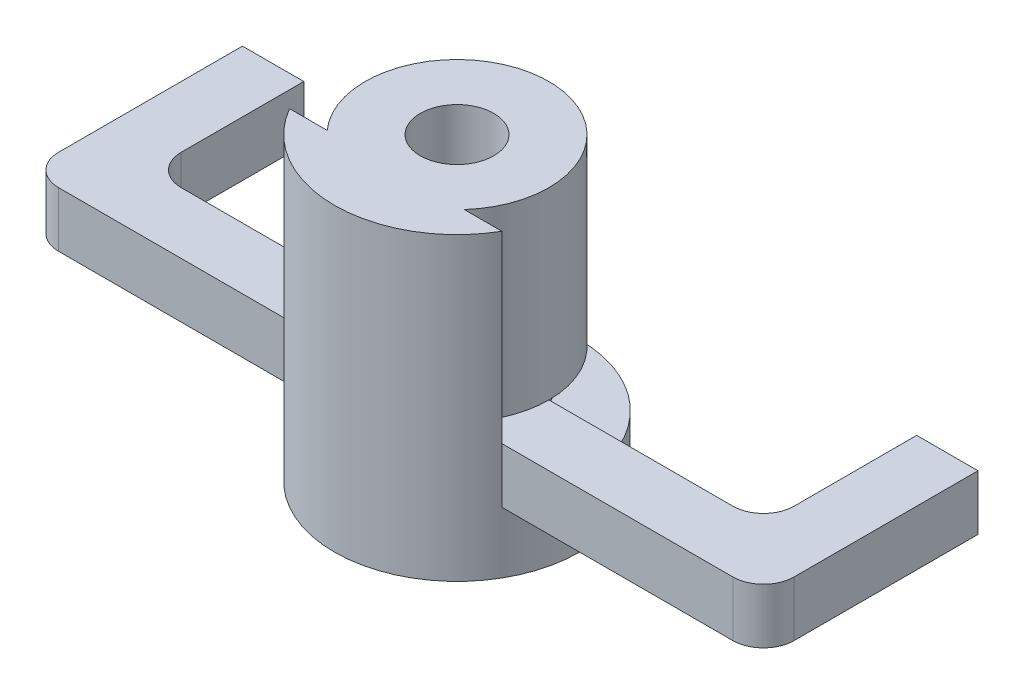
from build123d import *
from build123d.topology import SkipClean

# Parameters (mm, degrees)
BOSS_EXTRU_1_DEPTH      = 1.8
CONG_1_R                = 1
ESQUISSE4_R             = 4
BOSS_EXTRU_3_DEPTH      = 2
ENL_V_MAT_EXTRU_1_DEPTH = 11
ESQUISSE6_R             = 3
ESQUISSE6_R_2           = 1.2
BOSS_EXTRU_4_DEPTH      = 6
BOSS_EXTRU_5_DEPTH      = 6


with BuildPart() as part:
    # Esquisse1 → Boss.-Extru.1 (new body)
    with BuildSketch(Plane(origin=(0, 0, 0), x_dir=(1, 0, 0), z_dir=(0, 1, 0))):
        with BuildLine():
            Line((-10, 0), (-12, 0))
            Line((-12, 0), (-12, -7))
            Line((-12, -7), (-3.464101615, -7))
            ThreePointArc((-3.464101615, -7), (0, -9), (3.464101615, -7))
            Line((3.464101615, -7), (12, -7))
            Line((12, -7), (12, 0))
            Line((12, 0), (10, 0))
            Line((10, 0), (10, -5))
            Line((10, -5), (2, -5))
            ThreePointArc((2, -5), (0, -7), (-2, -5))
            Line((-2, -5), (-10, -5))
            Line((-10, -5), (-10, 0))
        make_face()
    extrude(amount=BOSS_EXTRU_1_DEPTH)

    # Congé1
    cong_1_edges = [part.edges().sort_by_distance(p)[0] for p in [
        (-10, 0.9, 5),
        (10, 0.9, 5),
        (12, 0.9, 7),
        (-12, 0.9, 7),
    ]]
    fillet(cong_1_edges, radius=CONG_1_R)

    # Esquisse4 → Boss.-Extru.3 (add)
    with SkipClean():  # keep this step's faces unmerged: merging them makes the solid invalid here
        with BuildSketch(Plane.XZ):
            with Locations(Location((0, 5, 0), (0, 0, 270))):  # turned: the seam where the file's is
                Circle(ESQUISSE4_R)
        extrude(amount=BOSS_EXTRU_3_DEPTH)

    # Esquisse5 → Enlèv. mat.-Extru.1 (cut)
    with SkipClean():  # keep this step's faces unmerged: merging them makes the solid invalid here
        with BuildSketch(Plane.XZ.offset(2)):
            Polygon((-1.15, 6.991858429), (-2.3, 5), (-1.15, 3.008141571), (1.15, 3.008141571), (2.3, 5), (1.15, 6.991858429), align=None)
        extrude(amount=-ENL_V_MAT_EXTRU_1_DEPTH, mode=Mode.SUBTRACT)

    # Esquisse6 → Boss.-Extru.4 (add)
    with SkipClean():  # keep this step's faces unmerged: merging them makes the solid invalid here
        with BuildSketch(Plane(origin=(0, 1.8, 0), x_dir=(1, 0, 0), z_dir=(0, 1, 0))):
            with Locations(Location((0, -5, 0), (0, 0, 180))):  # turned: the seam where the file's is
                Circle(ESQUISSE6_R)
            with Locations(Location((0, -5, 0), (0, 0, 270))):  # turned: the seam where the file's is
                Circle(ESQUISSE6_R_2, mode=Mode.SUBTRACT)
        extrude(amount=BOSS_EXTRU_4_DEPTH)

    # Esquisse7 → Boss.-Extru.5 (add)
    with SkipClean():  # keep this step's faces unmerged: merging them makes the solid invalid here
        with BuildSketch(Plane(origin=(0, 1.8, 0), x_dir=(1, 0, 0), z_dir=(0, 1, 0))):
            with BuildLine():
                Line((-3.464101615, -7), (3.464101615, -7))
                ThreePointArc((3.464101615, -7), (0, -9), (-3.464101615, -7))
            make_face()
        extrude(amount=BOSS_EXTRU_5_DEPTH)


solid = part.part
